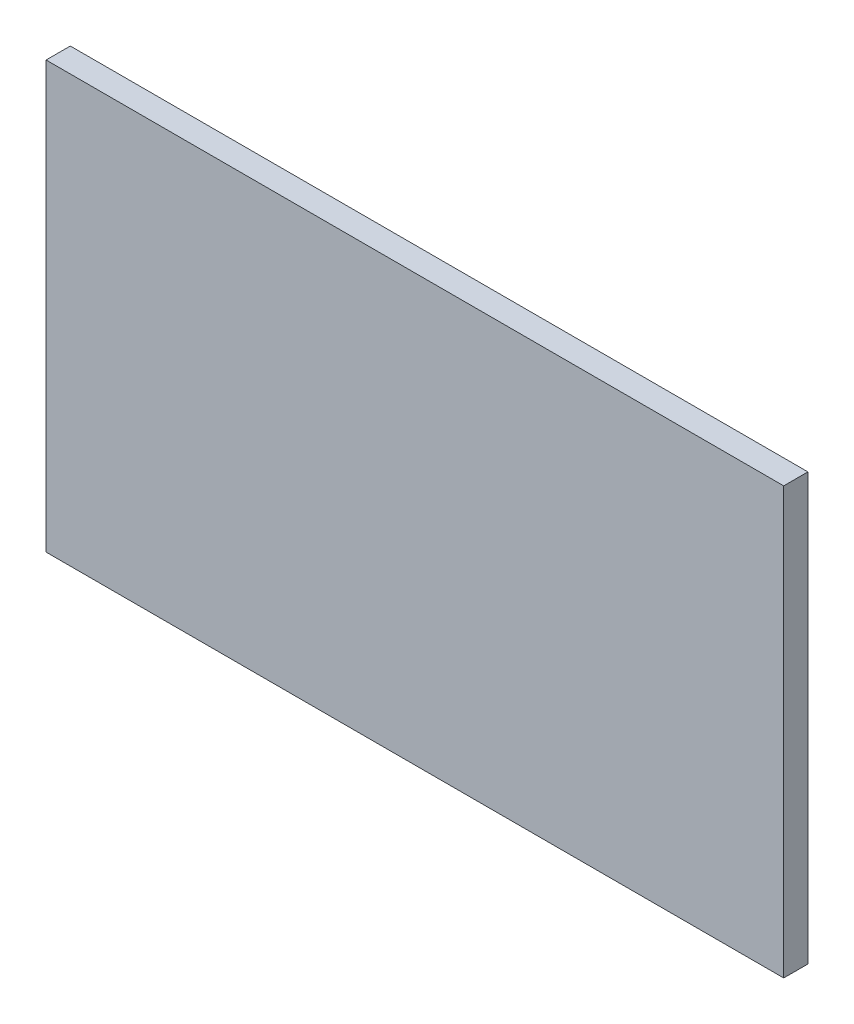
from build123d import *

# Parameters (mm, degrees)
SKETCH1_W           = 193.49
SKETCH1_H           = 111.8
BOSS_EXTRUDE1_DEPTH = 6.35


with BuildPart() as part:
    # Sketch1 → Boss-Extrude1 (new body)
    with BuildSketch(Plane.XY):
        with Locations((96.745, 55.9)):
            Rectangle(SKETCH1_W, SKETCH1_H)
    extrude(amount=BOSS_EXTRUDE1_DEPTH)


solid = part.part
